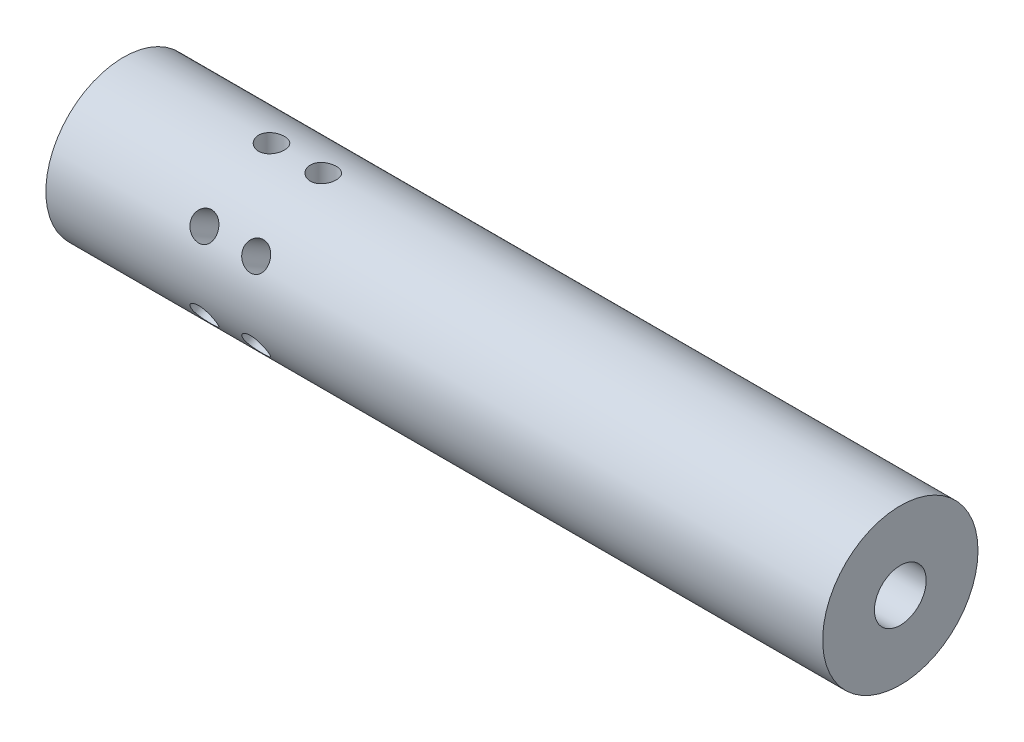
from build123d import *

# Parameters (mm, degrees)
SKETCH1_R                   = 1.5
SKETCH1_R_2                 = 0.5
EXTRUDE1_DEPTH              = 7.5
SKETCH3_R                   = 0.25
CUT_EXTRUDE1_DEPTH          = 10
LPATTERN1_COUNT             = 2
LPATTERN1_PITCH             = 1
CIRPATTERN1_COUNT           = 6
CIRPATTERN1_COPY_1_SKETCH_R = 0.25
CIRPATTERN1_COPY_1_DEPTH    = 10
CIRPATTERN1_COPY_2_SKETCH_R = 0.25
CIRPATTERN1_COPY_2_DEPTH    = 10
CIRPATTERN1_COPY_3_SKETCH_R = 0.25
CIRPATTERN1_COPY_3_DEPTH    = 10
CIRPATTERN1_COPY_4_SKETCH_R = 0.25
CIRPATTERN1_COPY_4_DEPTH    = 10
CIRPATTERN1_COPY_5_SKETCH_R = 0.25
CIRPATTERN1_COPY_5_DEPTH    = 10


with BuildPart() as part:
    # Sketch1 → Extrude1 (new body, symmetric)
    with BuildSketch(Plane(origin=(0, 0, 0), x_dir=(0, 0, -1), z_dir=(1, 0, 0))):
        Circle(SKETCH1_R)
        Circle(SKETCH1_R_2, mode=Mode.SUBTRACT)
    extrude(amount=EXTRUDE1_DEPTH, both=True)

    # Sketch3 → Cut-Extrude1 (cut)
    with BuildSketch(Plane(origin=(0, 0, 0), x_dir=(1, 0, 0), z_dir=(0, 1, 0))):
        with Locations((-4.642829353, 0)):
            Circle(SKETCH3_R)
    cut_extrude1 = extrude(amount=-CUT_EXTRUDE1_DEPTH, mode=Mode.SUBTRACT)

    # LPattern1: Cut-Extrude1 ×2
    with Locations(*[(i * LPATTERN1_PITCH, 0, 0) for i in range(1, LPATTERN1_COUNT)]):
        add(cut_extrude1, mode=Mode.SUBTRACT)

    # CirPattern1: Cut-Extrude1 ×6 about axis
    cirpattern1_axis = Axis((7.5, 0, 0), (-1, 0, 0))
    for i in range(1, CIRPATTERN1_COUNT):
        add(cut_extrude1.rotate(cirpattern1_axis, i * 360 / CIRPATTERN1_COUNT), mode=Mode.SUBTRACT)

    # CirPattern1 copy 1 sketch → CirPattern1 copy 1 (cut)
    with BuildSketch(Plane(origin=(1, 0, 0), x_dir=(1, 0, 0), z_dir=(0, 0.5, -0.866025404))):
        with Locations((-4.642829353, 0)):
            Circle(CIRPATTERN1_COPY_1_SKETCH_R)
    extrude(amount=-CIRPATTERN1_COPY_1_DEPTH, mode=Mode.SUBTRACT)

    # CirPattern1 copy 2 sketch → CirPattern1 copy 2 (cut)
    with BuildSketch(Plane(origin=(1, 0, 0), x_dir=(1, 0, 0), z_dir=(0, -0.5, -0.866025404))):
        with Locations((-4.642829353, 0)):
            Circle(CIRPATTERN1_COPY_2_SKETCH_R)
    extrude(amount=-CIRPATTERN1_COPY_2_DEPTH, mode=Mode.SUBTRACT)

    # CirPattern1 copy 3 sketch → CirPattern1 copy 3 (cut)
    with BuildSketch(Plane(origin=(1, 0, 0), x_dir=(1, 0, 0), z_dir=(0, -1, 0))):
        with Locations((-4.642829353, 0)):
            Circle(CIRPATTERN1_COPY_3_SKETCH_R)
    extrude(amount=-CIRPATTERN1_COPY_3_DEPTH, mode=Mode.SUBTRACT)

    # CirPattern1 copy 4 sketch → CirPattern1 copy 4 (cut)
    with BuildSketch(Plane(origin=(1, 0, 0), x_dir=(1, 0, 0), z_dir=(0, -0.5, 0.866025404))):
        with Locations((-4.642829353, 0)):
            Circle(CIRPATTERN1_COPY_4_SKETCH_R)
    extrude(amount=-CIRPATTERN1_COPY_4_DEPTH, mode=Mode.SUBTRACT)

    # CirPattern1 copy 5 sketch → CirPattern1 copy 5 (cut)
    with BuildSketch(Plane(origin=(1, 0, 0), x_dir=(1, 0, 0), z_dir=(0, 0.5, 0.866025404))):
        with Locations((-4.642829353, 0)):
            Circle(CIRPATTERN1_COPY_5_SKETCH_R)
    extrude(amount=-CIRPATTERN1_COPY_5_DEPTH, mode=Mode.SUBTRACT)


solid = part.part
